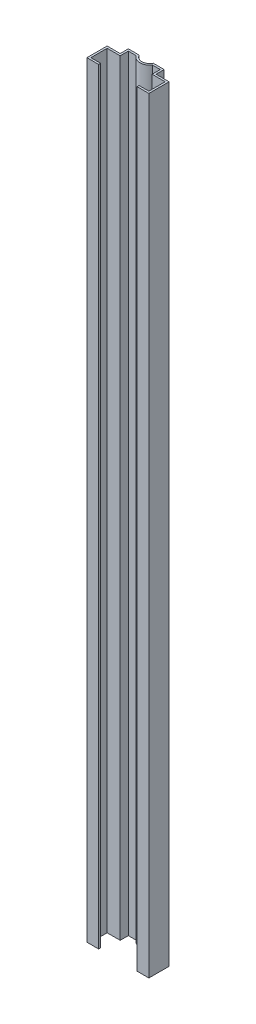
from build123d import *

# Parameters (mm, degrees)
BOSS_EXTRUDE1_DEPTH = 2350


with BuildPart() as part:
    # Sketch1 → Boss-Extrude1 (new body)
    with BuildSketch(Plane(origin=(0, 2350, 0), x_dir=(1, 0, 0), z_dir=(0, 1, 0))):
        with BuildLine():
            Line((25, 75), (49, 75))
            Line((49, 75), (49, 50))
            Line((49, 50), (89, 50))
            Line((89, 50), (89, 0))
            Line((89, 0), (59, 0))
            Line((59, 0), (59, -6))
            Line((59, -6), (95, -6))
            Line((95, -6), (95, 56))
            Line((95, 56), (55, 56))
            Line((55, 56), (55, 81))
            Line((55, 81), (21.540600907, 81))
            ThreePointArc((21.540600907, 81), (0, 67.583123952), (-21.540600907, 81))
            Line((-21.540600907, 81), (-55, 81))
            Line((-55, 81), (-55, 56))
            Line((-55, 56), (-95, 56))
            Line((-95, 56), (-95, -6))
            Line((-95, -6), (-59, -6))
            Line((-59, -6), (-59, 0))
            Line((-59, 0), (-89, 0))
            Line((-89, 0), (-89, 50))
            Line((-89, 50), (-49, 50))
            Line((-49, 50), (-49, 75))
            Line((-49, 75), (-25, 75))
            ThreePointArc((-25, 75), (0, 61.583123952), (25, 75))
        make_face()
    extrude(amount=-BOSS_EXTRUDE1_DEPTH)


solid = part.part
